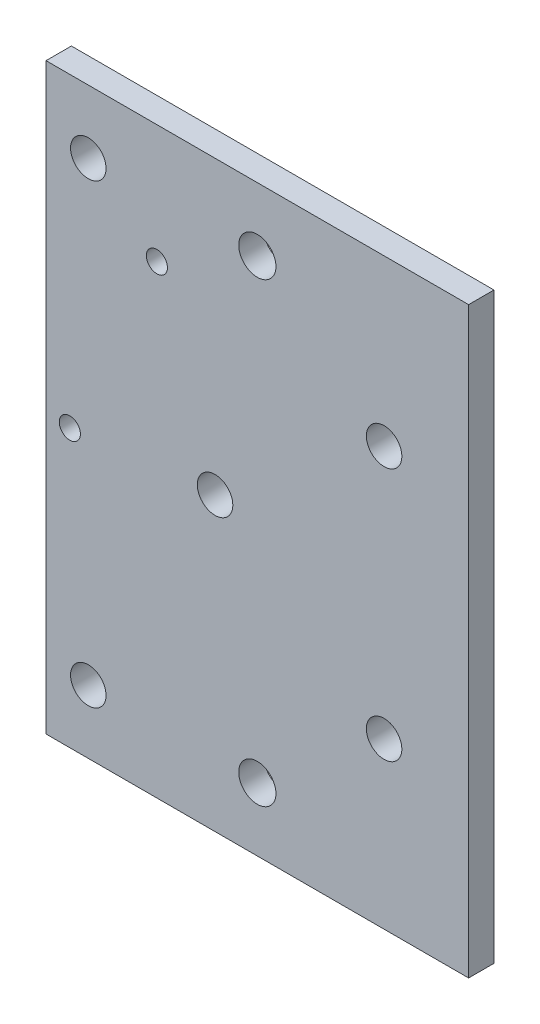
from build123d import *

# Parameters (mm, degrees)
SKETCH_1_W          = 40
SKETCH_1_H          = 29
EXTRUDE_1_DEPTH     = 3
SKETCH_3_W          = 40
SKETCH_3_H          = 3
EXTRUDE_2_DEPTH     = 3
SKETCH_4_W          = 40
SKETCH_4_H          = 3
EXTRUDE_3_DEPTH     = 3
SKETCH_5_W          = 40
SKETCH_5_H          = 3
EXTRUDE_4_DEPTH     = 7
SKETCH_6_W          = 40
SKETCH_6_H          = 3
EXTRUDE_5_DEPTH     = 7
SKETCH_7_W          = 40
SKETCH_7_H          = 3
EXTRUDE_6_DEPTH     = 10
SKETCH_8_W          = 40
SKETCH_8_H          = 3
EXTRUDE_7_DEPTH     = 10
SKETCH_9_R          = 2.2
CUT_EXTRUDE_2_DEPTH = 15
CUT_EXTRUDE_3_DEPTH = 4
SKETCH_12_W         = 3
SKETCH_12_H         = 69
EXTRUDE_9_DEPTH     = 30
SKETCH_15_R         = 2.1
CUT_EXTRUDE_4_DEPTH = 10
SKETCH_16_R         = 2.1
CUT_EXTRUDE_5_DEPTH = 10
SKETCH_17_W         = 3
SKETCH_17_H         = 69
CUT_EXTRUDE_6_DEPTH = 20
M3X0_5_1_D          = 2.5
M3X0_5_1_DEPTH      = 8.5
M3X0_5_1_TIP        = 0.751075774
SKETCH_20_R         = 2.1
CUT_EXTRUDE_7_DEPTH = 10


with BuildPart() as part:
    # ｽｹｯﾁ1 → ﾎﾞｽ - 押し出し1 (new body)
    with BuildSketch(Plane.XY):
        Rectangle(SKETCH_1_W, SKETCH_1_H)
    extrude(amount=EXTRUDE_1_DEPTH)

    # ｽｹｯﾁ3 → ﾎﾞｽ - 押し出し2 (add)
    with BuildSketch(Plane(origin=(0, -14.5, 0), x_dir=(-1, 0, 0), z_dir=(0, -1, 0))):
        with Locations((0, -1.5)):
            Rectangle(SKETCH_3_W, SKETCH_3_H)
    extrude(amount=EXTRUDE_2_DEPTH)

    # ｽｹｯﾁ4 → ﾎﾞｽ - 押し出し3 (add)
    with BuildSketch(Plane(origin=(0, 14.5, 0), x_dir=(1, 0, 0), z_dir=(0, 1, 0))):
        with Locations((0, -1.5)):
            Rectangle(SKETCH_4_W, SKETCH_4_H)
    extrude(amount=EXTRUDE_3_DEPTH)

    # ｽｹｯﾁ5 → ﾎﾞｽ - 押し出し4 (add)
    with BuildSketch(Plane.XZ.offset(17.5)):
        with Locations((0, 1.5)):
            Rectangle(SKETCH_5_W, SKETCH_5_H)
    extrude(amount=EXTRUDE_4_DEPTH)

    # ｽｹｯﾁ6 → ﾎﾞｽ - 押し出し5 (add)
    with BuildSketch(Plane(origin=(0, 17.5, 0), x_dir=(1, 0, 0), z_dir=(0, 1, 0))):
        with Locations((0, -1.5)):
            Rectangle(SKETCH_6_W, SKETCH_6_H)
    extrude(amount=EXTRUDE_5_DEPTH)

    # ｽｹｯﾁ7 → ﾎﾞｽ - 押し出し6 (add)
    with BuildSketch(Plane(origin=(0, 24.5, 0), x_dir=(1, 0, 0), z_dir=(0, 1, 0))):
        with Locations((0, -1.5)):
            Rectangle(SKETCH_7_W, SKETCH_7_H)
    extrude(amount=EXTRUDE_6_DEPTH)

    # ｽｹｯﾁ8 → ﾎﾞｽ - 押し出し7 (add)
    with BuildSketch(Plane.XZ.offset(24.5)):
        with Locations((0, 1.5)):
            Rectangle(SKETCH_8_W, SKETCH_8_H)
    extrude(amount=EXTRUDE_7_DEPTH)

    # ｽｹｯﾁ9 → ｶｯﾄ - 押し出し2 (cut)
    with BuildSketch(Plane.XY.offset(3)):
        with Locations((-5, 27)):
            Circle(SKETCH_9_R)
    extrude(amount=-CUT_EXTRUDE_2_DEPTH, mode=Mode.SUBTRACT)

    # ｽｹｯﾁ10 → ｶｯﾄ - 押し出し3 (cut, through all)
    with BuildSketch(Plane.XY.offset(3)):
        with BuildLine():
            ThreePointArc((-7.2, -27), (-5, -29.2), (-2.8, -27))
            Line((-2.8, -27), (-5, -27))
            Line((-5, -27), (-7.2, -27))
        make_face()
        with BuildLine():
            Line((-5, -27), (-2.8, -27))
            ThreePointArc((-2.8, -27), (-5, -24.8), (-7.2, -27))
            Line((-7.2, -27), (-5, -27))
        make_face()
    extrude(amount=-CUT_EXTRUDE_3_DEPTH, mode=Mode.SUBTRACT)

    # ｽｹｯﾁ12 → ﾎﾞｽ - 押し出し9 (add)
    with BuildSketch(Plane.ZY.offset(20)):
        with Locations((1.5, 0)):
            Rectangle(SKETCH_12_W, SKETCH_12_H)
    extrude(amount=EXTRUDE_9_DEPTH)

    # ｽｹｯﾁ15 → ｶｯﾄ - 押し出し4 (cut)
    with BuildSketch(Plane.XY.offset(3)):
        with Locations((-10, 0)):
            Circle(SKETCH_15_R)
    extrude(amount=-CUT_EXTRUDE_4_DEPTH, mode=Mode.SUBTRACT)

    # ｽｹｯﾁ16 → ｶｯﾄ - 押し出し5 (cut)
    with BuildSketch(Plane(origin=(0, 0, 0), x_dir=(-1, 0, 0), z_dir=(0, 0, -1))):
        with Locations((-10, -15)):
            Circle(SKETCH_16_R)
        with Locations((-10, 15)):
            Circle(SKETCH_16_R)
    extrude(amount=-CUT_EXTRUDE_5_DEPTH, mode=Mode.SUBTRACT)

    # ｽｹｯﾁ17 → ｶｯﾄ - 押し出し6 (cut)
    with BuildSketch(Plane.ZY.offset(50)):
        with Locations((1.5, 0)):
            Rectangle(SKETCH_17_W, SKETCH_17_H)
    extrude(amount=-CUT_EXTRUDE_6_DEPTH, mode=Mode.SUBTRACT)

    # M3x0.5 ねじ穴1
    with Locations(Plane(origin=(-16.881888018, 20.463438375, 3), x_dir=(1, 0, 0), z_dir=(0, 0, 1))):
        with Locations((0, 0), (-10.3, -22.2)):
            Hole(M3X0_5_1_D / 2, depth=M3X0_5_1_DEPTH)
            with Locations((0, 0, -(M3X0_5_1_DEPTH + M3X0_5_1_TIP / 2))):  # 118° drill point
                Cone(0, M3X0_5_1_D / 2, M3X0_5_1_TIP, mode=Mode.SUBTRACT)

    # ｽｹｯﾁ20 → ｶｯﾄ - 押し出し7 (cut)
    with BuildSketch(Plane(origin=(0, 0, 0), x_dir=(-1, 0, 0), z_dir=(0, 0, -1))):
        with Locations((25, -27)):
            Circle(SKETCH_20_R)
        with Locations((25, 27)):
            Circle(SKETCH_20_R)
    extrude(amount=-CUT_EXTRUDE_7_DEPTH, mode=Mode.SUBTRACT)


solid = part.part
